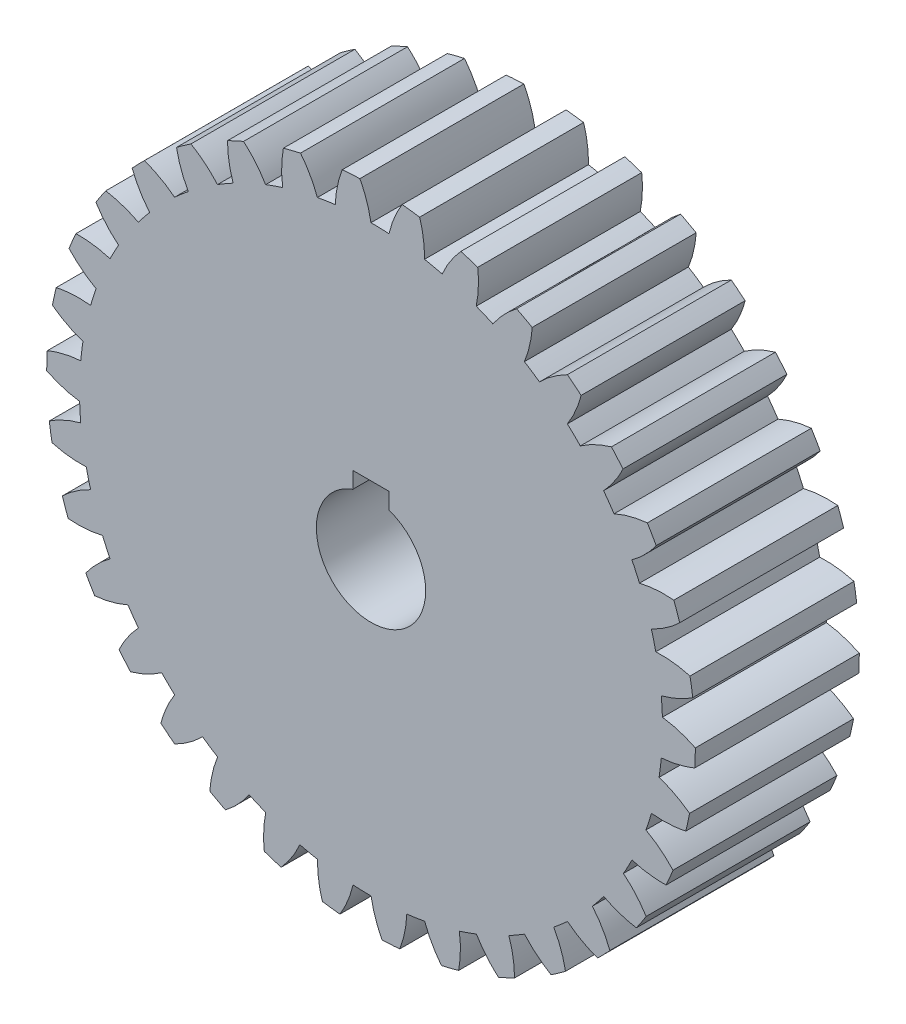
from build123d import *

# Parameters (mm, degrees)
SKETCH2_R           = 32
BOSS_EXTRUDE1_DEPTH = 18
BOSS_EXTRUDE2_DEPTH = 18
SKETCH4_R           = 6
CUT_EXTRUDE1_DEPTH  = 19.0000001
SKETCH5_W           = 4
SKETCH5_H           = 1.8
CUT_EXTRUDE2_DEPTH  = 8


with BuildPart() as part:
    # Sketch2 → Boss-Extrude1 (new body)
    with BuildSketch(Plane.XY):
        Circle(SKETCH2_R)
    extrude(amount=BOSS_EXTRUDE1_DEPTH)

    # Sketch3 → Boss-Extrude2 (add, through all)
    with BuildSketch(Plane.XY.offset(18)):
        with BuildLine():
            ThreePointArc((-0.008509696, 31.999998869), (-1.971036576, 31.939239421), (-3.926142805, 31.75823362))
            add(Edge.make_bspline(
                [(-3.926142805, 31.75823362), (-3.892964148, 32.765673981), (-3.66447612, 34.011686671), (-3.255661122, 35.204043024), (-3.15948732, 35.459521146)],
                knots=[0.00450438, 0.00450438, 0.00450438, 0.00450438, 0.249370947, 0.316995121, 0.316995121, 0.316995121, 0.316995121], degree=3))
            ThreePointArc((-3.15948732, 35.459521146), (-2.1927782, 35.532403856), (-1.224442977, 35.578936738))
            add(Edge.make_bspline(
                [(-0.008509696, 31.999998869), (-0.165307213, 32.995715259), (-0.545266131, 34.204179473), (-1.097586389, 35.337222282), (-1.224442977, 35.578936738)],
                knots=[0.004504381, 0.004504381, 0.004504381, 0.004504381, 0.249370947, 0.316995114, 0.316995114, 0.316995114, 0.316995114], degree=3))
        make_face()
        with BuildLine():
            ThreePointArc((5.334017961, 35.198128535), (4.373620091, 35.330319094), (3.409978868, 35.436309685))
            add(Edge.make_bspline(
                [(1.976267352, 31.938916189), (2.193997759, 32.923106401), (2.647549576, 34.105918793), (3.268498626, 35.202853454), (3.409978868, 35.436309685)],
                knots=[0.00450438, 0.00450438, 0.00450438, 0.00450438, 0.249370947, 0.316995121, 0.316995121, 0.316995121, 0.316995121], degree=3))
            ThreePointArc((1.976267352, 31.938916189), (3.931343911, 31.757590196), (5.87161956, 31.45670173))
            add(Edge.make_bspline(
                [(5.87161956, 31.45670173), (5.900454225, 32.464275625), (5.749019546, 33.721980707), (5.41429966, 34.937219891), (5.334017961, 35.198128535)],
                knots=[0.004504381, 0.004504381, 0.004504381, 0.004504381, 0.249370947, 0.316995114, 0.316995114, 0.316995114, 0.316995114], degree=3))
        make_face()
        with BuildLine():
            ThreePointArc((11.710835316, 33.618690281), (10.791079996, 33.92510269), (9.863322315, 34.2063572))
            add(Edge.make_bspline(
                [(7.811378094, 31.031957274), (8.206245705, 31.95938192), (8.869416146, 33.038714755), (9.681353574, 34.002872931), (9.863322315, 34.2063572)],
                knots=[0.00450438, 0.00450438, 0.00450438, 0.00450438, 0.249370947, 0.316995121, 0.316995121, 0.316995121, 0.316995121], degree=3))
            ThreePointArc((7.811378094, 31.031957274), (9.699847195, 30.494474326), (11.551797854, 29.842184343))
            add(Edge.make_bspline(
                [(11.551797854, 29.842184343), (11.765282772, 30.827304021), (11.847529259, 32.091420334), (11.741808228, 33.347472378), (11.710835316, 33.618690281)],
                knots=[0.004504381, 0.004504381, 0.004504381, 0.004504381, 0.249370947, 0.316995114, 0.316995114, 0.316995114, 0.316995114], degree=3))
        make_face()
        with BuildLine():
            ThreePointArc((17.688854219, 30.89440785), (16.841062613, 31.364607602), (15.980782151, 31.811548246))
            add(Edge.make_bspline(
                [(13.380481724, 29.068242273), (13.939039795, 29.907319019), (14.789245387, 30.846416912), (15.764521637, 31.644965352), (15.980782151, 31.811548246)],
                knots=[0.00450438, 0.00450438, 0.00450438, 0.00450438, 0.249370947, 0.316995121, 0.316995121, 0.316995121, 0.316995121], degree=3))
            ThreePointArc((13.380481724, 29.068242273), (15.138033817, 28.192905706), (16.838593527, 27.211427159))
            add(Edge.make_bspline(
                [(16.838593527, 27.211427159), (17.229458724, 28.140545553), (17.542585571, 29.36802513), (17.6694636, 30.62211669), (17.688854219, 30.89440785)],
                knots=[0.004504381, 0.004504381, 0.004504381, 0.004504381, 0.249370947, 0.316995114, 0.316995114, 0.316995114, 0.316995114], degree=3))
        make_face()
        with BuildLine():
            ThreePointArc((23.064500407, 27.118053414), (22.317543043, 27.73602842), (21.554035618, 28.333435171))
            add(Edge.make_bspline(
                [(18.493929097, 26.114643144), (19.197156602, 26.836798238), (20.205444614, 27.603681338), (21.310847823, 28.209426432), (21.554035618, 28.333435171)],
                knots=[0.00450438, 0.00450438, 0.00450438, 0.00450438, 0.249370947, 0.316995121, 0.316995121, 0.316995121, 0.316995121], degree=3))
            ThreePointArc((18.493929097, 26.114643144), (20.060712854, 24.931261496), (21.551971093, 23.65401746))
            add(Edge.make_bspline(
                [(21.551971093, 23.65401746), (22.106906124, 24.495494556), (22.640250172, 25.644537054), (22.995406581, 26.853961545), (23.064500407, 27.118053414)],
                knots=[0.004504381, 0.004504381, 0.004504381, 0.004504381, 0.249370947, 0.316995114, 0.316995114, 0.316995114, 0.316995114], degree=3))
        make_face()
        with BuildLine():
            ThreePointArc((27.654712697, 22.418226193), (27.03402631, 23.162932056), (26.393292253, 23.890460943))
            add(Edge.make_bspline(
                [(22.977587896, 22.271741165), (23.801537266, 22.85238248), (24.933571658, 23.420935502), (26.131458646, 23.813249328), (26.393292253, 23.890460943)],
                knots=[0.00450438, 0.00450438, 0.00450438, 0.00450438, 0.249370947, 0.316995121, 0.316995121, 0.316995121, 0.316995121], degree=3))
            ThreePointArc((22.977587896, 22.271741165), (24.300248374, 20.820613078), (25.531422133, 19.291098566))
            add(Edge.make_bspline(
                [(25.531422133, 19.291098566), (26.231529351, 20.016278871), (26.966928208, 21.047755025), (27.538268571, 22.171326948), (27.654712697, 22.418226193)],
                knots=[0.004504381, 0.004504381, 0.004504381, 0.004504381, 0.249370947, 0.316995114, 0.316995114, 0.316995114, 0.316995114], degree=3))
        make_face()
        with BuildLine():
            ThreePointArc((31.303176914, 16.954973167), (30.829898236, 17.801049822), (30.333756975, 18.633925721))
            add(Edge.make_bspline(
                [(26.678772497, 17.670401752), (27.595385126, 18.089756246), (28.812615825, 18.440617799), (30.062193987, 18.60614058), (30.333756975, 18.633925721)],
                knots=[0.00450438, 0.00450438, 0.00450438, 0.00450438, 0.249370947, 0.316995121, 0.316995121, 0.316995121, 0.316995121], degree=3))
            ThreePointArc((26.678772497, 17.670401752), (27.712268081, 16.000943653), (28.641431213, 14.271244448))
            add(Edge.make_bspline(
                [(28.641431213, 14.271244448), (29.462869307, 14.855432816), (30.375279846, 15.734216943), (31.143347853, 16.733674403), (31.303176914, 16.954973167)],
                knots=[0.004504381, 0.004504381, 0.004504381, 0.004504381, 0.249370947, 0.316995114, 0.316995114, 0.316995114, 0.316995114], degree=3))
        make_face()
        with BuildLine():
            ThreePointArc((33.885648985, 10.914338865), (33.575894953, 11.832974186), (33.241241985, 12.742834507))
            add(Edge.make_bspline(
                [(29.471443498, 12.467318), (30.449505242, 12.711105059), (31.710480916, 12.832326973), (32.969197366, 12.765422029), (33.241241985, 12.742834507)],
                knots=[0.00450438, 0.00450438, 0.00450438, 0.00450438, 0.249370947, 0.316995121, 0.316995121, 0.316995121, 0.316995121], degree=3))
            ThreePointArc((29.471443498, 12.467318), (30.180579736, 10.636381283), (30.776090704, 8.765400216))
            add(Edge.make_bspline(
                [(30.776090704, 8.765400216), (31.690886585, 9.188702814), (32.749237761, 9.884868975), (33.687877776, 10.726176645), (33.885648985, 10.914338865)],
                knots=[0.004504381, 0.004504381, 0.004504381, 0.004504381, 0.249370947, 0.316995114, 0.316995114, 0.316995114, 0.316995114], degree=3))
        make_face()
        with BuildLine():
            ThreePointArc((35.314185921, 4.502029843), (35.178504838, 5.461940806), (35.016736368, 6.417801348))
            add(Edge.make_bspline(
                [(31.260499839, 6.839674687), (32.266703977, 6.899592434), (33.528483612, 6.787046642), (34.753474272, 6.489992342), (35.016736368, 6.417801348)],
                knots=[0.00450438, 0.00450438, 0.00450438, 0.00450438, 0.249370947, 0.316995121, 0.316995121, 0.316995121, 0.316995121], degree=3))
            ThreePointArc((31.260499839, 6.839674687), (31.621127945, 4.909609705), (31.862707339, 2.961060793))
            add(Edge.make_bspline(
                [(31.862707339, 2.961060793), (32.839708729, 3.209062558), (34.007959662, 3.698903649), (35.085207426, 4.353411807), (35.314185921, 4.502029843)],
                knots=[0.004504381, 0.004504381, 0.004504381, 0.004504381, 0.249370947, 0.316995114, 0.316995114, 0.316995114, 0.316995114], degree=3))
        make_face()
        with BuildLine():
            ThreePointArc((35.540140611, -2.063590405), (35.583152932, -1.095092417), (35.599777791, -0.125782339))
            add(Edge.make_bspline(
                [(31.98501735, 0.979114456), (32.985098808, 0.853122464), (34.204714012, 0.510641579), (35.354263293, -0.006446251), (35.599777791, -0.125782339)],
                knots=[0.00450438, 0.00450438, 0.00450438, 0.00450438, 0.249370947, 0.316995121, 0.316995121, 0.316995121, 0.316995121], degree=3))
            ThreePointArc((31.98501735, 0.979114456), (31.984856568, -0.984352743), (31.86427769, -2.944114004))
            add(Edge.make_bspline(
                [(31.86427769, -2.944114004), (32.87021398, -2.879858475), (34.108581285, -2.613023405), (35.287752417, -2.167603249), (35.540140611, -2.063590405)],
                knots=[0.004504381, 0.004504381, 0.004504381, 0.004504381, 0.249370947, 0.316995114, 0.316995114, 0.316995114, 0.316995114], degree=3))
        make_face()
        with BuildLine():
            ThreePointArc((34.555818438, -8.558937557), (34.776059431, -7.614833581), (34.97051148, -6.665082659))
            add(Edge.make_bspline(
                [(31.620323457, -4.914788344), (32.58022566, -5.222399568), (33.7161439, -5.783152771), (34.751105281, -6.502665324), (34.97051148, -6.665082659)],
                knots=[0.00450438, 0.00450438, 0.00450438, 0.00450438, 0.249370947, 0.316995121, 0.316995121, 0.316995121, 0.316995121], degree=3))
            ThreePointArc((31.620323457, -4.914788344), (31.259379262, -6.844794238), (30.780748282, -8.749030529))
            add(Edge.make_bspline(
                [(30.780748282, -8.749030529), (31.781363517, -8.870709381), (33.04767608, -8.83596708), (34.288615323, -8.614803176), (34.555818438, -8.558937557)],
                knots=[0.004504381, 0.004504381, 0.004504381, 0.004504381, 0.249370947, 0.316995114, 0.316995114, 0.316995114, 0.316995114], degree=3))
        make_face()
        with BuildLine():
            ThreePointArc((32.394739313, -14.762820356), (32.784708935, -13.875260721), (33.150366342, -12.977411583))
            add(Edge.make_bspline(
                [(30.178837373, -10.641323921), (31.065872003, -11.120079046), (32.079410945, -11.880008789), (32.964540058, -12.777443929), (33.150366342, -12.977411583)],
                knots=[0.00450438, 0.00450438, 0.00450438, 0.00450438, 0.249370947, 0.316995121, 0.316995121, 0.316995121, 0.316995121], degree=3))
            ThreePointArc((30.178837373, -10.641323921), (29.469401286, -12.472144476), (28.649017408, -14.256009313))
            add(Edge.make_bspline(
                [(28.649017408, -14.256009313), (29.610236837, -14.559478918), (30.861371904, -14.758012494), (32.121820558, -14.768636313), (32.394739313, -14.762820356)],
                knots=[0.004504381, 0.004504381, 0.004504381, 0.004504381, 0.249370947, 0.316995114, 0.316995114, 0.316995114, 0.316995114], degree=3))
        make_face()
        with BuildLine():
            ThreePointArc((29.130496193, -20.463973014), (29.676914497, -19.663182498), (30.201325238, -18.847810321))
            add(Edge.make_bspline(
                [(27.709647178, -16.005481975), (28.493607334, -16.63907757), (29.350252126, -17.572305357), (30.055406959, -18.617102005), (30.201325238, -18.847810321)],
                knots=[0.00450438, 0.00450438, 0.00450438, 0.00450438, 0.249370947, 0.316995121, 0.316995121, 0.316995121, 0.316995121], degree=3))
            ThreePointArc((27.709647178, -16.005481975), (26.675878195, -17.674770792), (25.541678607, -19.277516798))
            add(Edge.make_bspline(
                [(25.541678607, -19.277516798), (26.430769055, -19.752442863), (27.624120721, -20.177491493), (28.86115572, -20.419541254), (29.130496193, -20.463973014)],
                knots=[0.004504381, 0.004504381, 0.004504381, 0.004504381, 0.249370947, 0.316995114, 0.316995114, 0.316995114, 0.316995114], degree=3))
        make_face()
        with BuildLine():
            ThreePointArc((24.874248965, -25.468249615), (25.558508329, -24.781498179), (26.223814225, -24.076369483))
            add(Edge.make_bspline(
                [(24.296838183, -20.824592537), (24.951027042, -21.591452263), (25.621605673, -22.666198141), (26.122773024, -23.822777002), (26.223814225, -24.076369483)],
                knots=[0.00450438, 0.00450438, 0.00450438, 0.00450438, 0.249370947, 0.316995121, 0.316995121, 0.316995121, 0.316995121], degree=3))
            ThreePointArc((24.296838183, -20.824592537), (22.973940065, -22.275503987), (21.564548575, -23.64255157))
            add(Edge.make_bspline(
                [(21.564548575, -23.64255157), (22.351233133, -24.272761057), (23.446163238, -24.90985022), (24.617658839, -25.375083207), (24.874248965, -25.468249615)],
                knots=[0.004504381, 0.004504381, 0.004504381, 0.004504381, 0.249370947, 0.316995114, 0.316995114, 0.316995114, 0.316995114], degree=3))
        make_face()
        with BuildLine():
            ThreePointArc((19.770939021, -29.605235521), (20.569737814, -29.055909661), (21.353282671, -28.485036759))
            add(Edge.make_bspline(
                [(20.056629504, -24.934546576), (20.558769449, -25.808555946), (21.020446168, -26.988220733), (21.300559385, -28.2171959), (21.353282671, -28.485036759)],
                knots=[0.00450438, 0.00450438, 0.00450438, 0.00450438, 0.249370947, 0.316995121, 0.316995121, 0.316995121, 0.316995121], degree=3))
            ThreePointArc((20.056629504, -24.934546576), (18.489651961, -26.117671611), (16.853063706, -27.202467604))
            add(Edge.make_bspline(
                [(16.853063706, -27.202467604), (17.510552775, -27.966499485), (18.469774787, -28.793933873), (19.535837112, -29.466507136), (19.770939021, -29.605235521)],
                knots=[0.004504381, 0.004504381, 0.004504381, 0.004504381, 0.249370947, 0.316995114, 0.316995114, 0.316995114, 0.316995114], degree=3))
        make_face()
        with BuildLine():
            ThreePointArc((13.994353461, -32.734050639), (14.880489549, -32.340856989), (15.755590686, -31.923680272))
            add(Edge.make_bspline(
                [(15.133416362, -28.195384537), (15.466407621, -29.14678021), (15.70346058, -30.391191837), (15.752980743, -31.650712034), (15.755590686, -31.923680272)],
                knots=[0.00450438, 0.00450438, 0.00450438, 0.00450438, 0.249370947, 0.316995121, 0.316995121, 0.316995121, 0.316995121], degree=3))
            ThreePointArc((15.133416362, -28.195384537), (13.375720935, -29.070433252), (11.567667964, -29.836036229))
            add(Edge.make_bspline(
                [(11.567667964, -29.836036229), (12.073571543, -30.707872315), (12.864420308, -31.697474642), (13.788745883, -32.554484506), (13.994353461, -32.734050639)],
                knots=[0.004504381, 0.004504381, 0.004504381, 0.004504381, 0.249370947, 0.316995114, 0.316995114, 0.316995114, 0.316995114], degree=3))
        make_face()
        with BuildLine():
            ThreePointArc((7.741206979, -34.748146922), (8.68450406, -34.52447522), (9.621360957, -34.275201142))
            add(Edge.make_bspline(
                [(9.694852877, -30.496062495), (9.84735583, -31.492445831), (9.851712476, -32.759227353), (9.668953235, -34.006401131), (9.621360957, -34.275201142)],
                knots=[0.00450438, 0.00450438, 0.00450438, 0.00450438, 0.249370947, 0.316995121, 0.316995121, 0.316995121, 0.316995121], degree=3))
            ThreePointArc((9.694852877, -30.496062495), (7.806295776, -31.033236155), (5.888349164, -31.453574425))
            add(Edge.make_bspline(
                [(5.888349164, -31.453574425), (6.225439312, -32.403525384), (6.820983424, -33.52159593), (7.572095451, -34.533857951), (7.741206979, -34.748146922)],
                knots=[0.004504381, 0.004504381, 0.004504381, 0.004504381, 0.249370947, 0.316995114, 0.316995114, 0.316995114, 0.316995114], degree=3))
        make_face()
        with BuildLine():
            ThreePointArc((1.224442977, -35.578936738), (2.1927782, -35.532403856), (3.15948732, -35.459521146))
            add(Edge.make_bspline(
                [(3.926142805, -31.75823362), (3.892964148, -32.765673981), (3.66447612, -34.011686671), (3.255661122, -35.204043024), (3.15948732, -35.459521146)],
                knots=[0.00450438, 0.00450438, 0.00450438, 0.00450438, 0.249370947, 0.316995121, 0.316995121, 0.316995121, 0.316995121], degree=3))
            ThreePointArc((3.926142805, -31.75823362), (1.971036576, -31.939239421), (0.008509696, -31.999998869))
            add(Edge.make_bspline(
                [(0.008509696, -31.999998869), (0.165307213, -32.995715259), (0.545266131, -34.204179473), (1.097586389, -35.337222282), (1.224442977, -35.578936738)],
                knots=[0.004504381, 0.004504381, 0.004504381, 0.004504381, 0.249370947, 0.316995114, 0.316995114, 0.316995114, 0.316995114], degree=3))
        make_face()
        with BuildLine():
            ThreePointArc((-5.334017961, -35.198128535), (-4.373620091, -35.330319094), (-3.409978868, -35.436309685))
            add(Edge.make_bspline(
                [(-1.976267352, -31.938916189), (-2.193997759, -32.923106401), (-2.647549576, -34.105918793), (-3.268498626, -35.202853454), (-3.409978868, -35.436309685)],
                knots=[0.00450438, 0.00450438, 0.00450438, 0.00450438, 0.249370947, 0.316995121, 0.316995121, 0.316995121, 0.316995121], degree=3))
            ThreePointArc((-1.976267352, -31.938916189), (-3.931343911, -31.757590196), (-5.87161956, -31.45670173))
            add(Edge.make_bspline(
                [(-5.87161956, -31.45670173), (-5.900454225, -32.464275625), (-5.749019546, -33.721980707), (-5.41429966, -34.937219891), (-5.334017961, -35.198128535)],
                knots=[0.004504381, 0.004504381, 0.004504381, 0.004504381, 0.249370947, 0.316995114, 0.316995114, 0.316995114, 0.316995114], degree=3))
        make_face()
        with BuildLine():
            ThreePointArc((-11.710835316, -33.618690281), (-10.791079996, -33.92510269), (-9.863322315, -34.2063572))
            add(Edge.make_bspline(
                [(-7.811378094, -31.031957274), (-8.206245705, -31.95938192), (-8.869416146, -33.038714755), (-9.681353574, -34.002872931), (-9.863322315, -34.2063572)],
                knots=[0.00450438, 0.00450438, 0.00450438, 0.00450438, 0.249370947, 0.316995121, 0.316995121, 0.316995121, 0.316995121], degree=3))
            ThreePointArc((-7.811378094, -31.031957274), (-9.699847195, -30.494474326), (-11.551797854, -29.842184343))
            add(Edge.make_bspline(
                [(-11.551797854, -29.842184343), (-11.765282772, -30.827304021), (-11.847529259, -32.091420334), (-11.741808228, -33.347472378), (-11.710835316, -33.618690281)],
                knots=[0.004504381, 0.004504381, 0.004504381, 0.004504381, 0.249370947, 0.316995114, 0.316995114, 0.316995114, 0.316995114], degree=3))
        make_face()
        with BuildLine():
            ThreePointArc((-17.688854219, -30.89440785), (-16.841062613, -31.364607602), (-15.980782151, -31.811548246))
            add(Edge.make_bspline(
                [(-13.380481724, -29.068242273), (-13.939039795, -29.907319019), (-14.789245387, -30.846416912), (-15.764521637, -31.644965352), (-15.980782151, -31.811548246)],
                knots=[0.00450438, 0.00450438, 0.00450438, 0.00450438, 0.249370947, 0.316995121, 0.316995121, 0.316995121, 0.316995121], degree=3))
            ThreePointArc((-13.380481724, -29.068242273), (-15.138033817, -28.192905706), (-16.838593527, -27.211427159))
            add(Edge.make_bspline(
                [(-16.838593527, -27.211427159), (-17.229458724, -28.140545553), (-17.542585571, -29.36802513), (-17.6694636, -30.62211669), (-17.688854219, -30.89440785)],
                knots=[0.004504381, 0.004504381, 0.004504381, 0.004504381, 0.249370947, 0.316995114, 0.316995114, 0.316995114, 0.316995114], degree=3))
        make_face()
        with BuildLine():
            ThreePointArc((-23.064500407, -27.118053414), (-22.317543043, -27.73602842), (-21.554035618, -28.333435171))
            add(Edge.make_bspline(
                [(-18.493929097, -26.114643144), (-19.197156602, -26.836798238), (-20.205444614, -27.603681338), (-21.310847823, -28.209426432), (-21.554035618, -28.333435171)],
                knots=[0.00450438, 0.00450438, 0.00450438, 0.00450438, 0.249370947, 0.316995121, 0.316995121, 0.316995121, 0.316995121], degree=3))
            ThreePointArc((-18.493929097, -26.114643144), (-20.060712854, -24.931261496), (-21.551971093, -23.65401746))
            add(Edge.make_bspline(
                [(-21.551971093, -23.65401746), (-22.106906124, -24.495494556), (-22.640250172, -25.644537054), (-22.995406581, -26.853961545), (-23.064500407, -27.118053414)],
                knots=[0.004504381, 0.004504381, 0.004504381, 0.004504381, 0.249370947, 0.316995114, 0.316995114, 0.316995114, 0.316995114], degree=3))
        make_face()
        with BuildLine():
            ThreePointArc((-27.654712697, -22.418226193), (-27.03402631, -23.162932056), (-26.393292253, -23.890460943))
            add(Edge.make_bspline(
                [(-22.977587896, -22.271741165), (-23.801537266, -22.85238248), (-24.933571658, -23.420935502), (-26.131458646, -23.813249328), (-26.393292253, -23.890460943)],
                knots=[0.00450438, 0.00450438, 0.00450438, 0.00450438, 0.249370947, 0.316995121, 0.316995121, 0.316995121, 0.316995121], degree=3))
            ThreePointArc((-22.977587896, -22.271741165), (-24.300248374, -20.820613078), (-25.531422133, -19.291098566))
            add(Edge.make_bspline(
                [(-25.531422133, -19.291098566), (-26.231529351, -20.016278871), (-26.966928208, -21.047755025), (-27.538268571, -22.171326948), (-27.654712697, -22.418226193)],
                knots=[0.004504381, 0.004504381, 0.004504381, 0.004504381, 0.249370947, 0.316995114, 0.316995114, 0.316995114, 0.316995114], degree=3))
        make_face()
        with BuildLine():
            ThreePointArc((-31.303176914, -16.954973167), (-30.829898236, -17.801049822), (-30.333756975, -18.633925721))
            add(Edge.make_bspline(
                [(-26.678772497, -17.670401752), (-27.595385126, -18.089756246), (-28.812615825, -18.440617799), (-30.062193987, -18.60614058), (-30.333756975, -18.633925721)],
                knots=[0.00450438, 0.00450438, 0.00450438, 0.00450438, 0.249370947, 0.316995121, 0.316995121, 0.316995121, 0.316995121], degree=3))
            ThreePointArc((-26.678772497, -17.670401752), (-27.712268081, -16.000943653), (-28.641431213, -14.271244448))
            add(Edge.make_bspline(
                [(-28.641431213, -14.271244448), (-29.462869307, -14.855432816), (-30.375279846, -15.734216943), (-31.143347853, -16.733674403), (-31.303176914, -16.954973167)],
                knots=[0.004504381, 0.004504381, 0.004504381, 0.004504381, 0.249370947, 0.316995114, 0.316995114, 0.316995114, 0.316995114], degree=3))
        make_face()
        with BuildLine():
            ThreePointArc((-33.885648985, -10.914338865), (-33.575894953, -11.832974186), (-33.241241985, -12.742834507))
            add(Edge.make_bspline(
                [(-29.471443498, -12.467318), (-30.449505242, -12.711105059), (-31.710480916, -12.832326973), (-32.969197366, -12.765422029), (-33.241241985, -12.742834507)],
                knots=[0.00450438, 0.00450438, 0.00450438, 0.00450438, 0.249370947, 0.316995121, 0.316995121, 0.316995121, 0.316995121], degree=3))
            ThreePointArc((-29.471443498, -12.467318), (-30.180579736, -10.636381283), (-30.776090704, -8.765400216))
            add(Edge.make_bspline(
                [(-30.776090704, -8.765400216), (-31.690886585, -9.188702814), (-32.749237761, -9.884868975), (-33.687877776, -10.726176645), (-33.885648985, -10.914338865)],
                knots=[0.004504381, 0.004504381, 0.004504381, 0.004504381, 0.249370947, 0.316995114, 0.316995114, 0.316995114, 0.316995114], degree=3))
        make_face()
        with BuildLine():
            ThreePointArc((-35.314185921, -4.502029843), (-35.178504838, -5.461940806), (-35.016736368, -6.417801348))
            add(Edge.make_bspline(
                [(-31.260499839, -6.839674687), (-32.266703977, -6.899592434), (-33.528483612, -6.787046642), (-34.753474272, -6.489992342), (-35.016736368, -6.417801348)],
                knots=[0.00450438, 0.00450438, 0.00450438, 0.00450438, 0.249370947, 0.316995121, 0.316995121, 0.316995121, 0.316995121], degree=3))
            ThreePointArc((-31.260499839, -6.839674687), (-31.621127945, -4.909609705), (-31.862707339, -2.961060793))
            add(Edge.make_bspline(
                [(-31.862707339, -2.961060793), (-32.839708729, -3.209062558), (-34.007959662, -3.698903649), (-35.085207426, -4.353411807), (-35.314185921, -4.502029843)],
                knots=[0.004504381, 0.004504381, 0.004504381, 0.004504381, 0.249370947, 0.316995114, 0.316995114, 0.316995114, 0.316995114], degree=3))
        make_face()
        with BuildLine():
            ThreePointArc((-35.540140611, 2.063590405), (-35.583152932, 1.095092417), (-35.599777791, 0.125782339))
            add(Edge.make_bspline(
                [(-31.98501735, -0.979114456), (-32.985098808, -0.853122464), (-34.204714012, -0.510641579), (-35.354263293, 0.006446251), (-35.599777791, 0.125782339)],
                knots=[0.00450438, 0.00450438, 0.00450438, 0.00450438, 0.249370947, 0.316995121, 0.316995121, 0.316995121, 0.316995121], degree=3))
            ThreePointArc((-31.98501735, -0.979114456), (-31.984856568, 0.984352743), (-31.86427769, 2.944114004))
            add(Edge.make_bspline(
                [(-31.86427769, 2.944114004), (-32.87021398, 2.879858475), (-34.108581285, 2.613023405), (-35.287752417, 2.167603249), (-35.540140611, 2.063590405)],
                knots=[0.004504381, 0.004504381, 0.004504381, 0.004504381, 0.249370947, 0.316995114, 0.316995114, 0.316995114, 0.316995114], degree=3))
        make_face()
        with BuildLine():
            ThreePointArc((-34.555818438, 8.558937557), (-34.776059431, 7.614833581), (-34.97051148, 6.665082659))
            add(Edge.make_bspline(
                [(-31.620323457, 4.914788344), (-32.58022566, 5.222399568), (-33.7161439, 5.783152771), (-34.751105281, 6.502665324), (-34.97051148, 6.665082659)],
                knots=[0.00450438, 0.00450438, 0.00450438, 0.00450438, 0.249370947, 0.316995121, 0.316995121, 0.316995121, 0.316995121], degree=3))
            ThreePointArc((-31.620323457, 4.914788344), (-31.259379262, 6.844794238), (-30.780748282, 8.749030529))
            add(Edge.make_bspline(
                [(-30.780748282, 8.749030529), (-31.781363517, 8.870709381), (-33.04767608, 8.83596708), (-34.288615323, 8.614803176), (-34.555818438, 8.558937557)],
                knots=[0.004504381, 0.004504381, 0.004504381, 0.004504381, 0.249370947, 0.316995114, 0.316995114, 0.316995114, 0.316995114], degree=3))
        make_face()
        with BuildLine():
            ThreePointArc((-32.394739313, 14.762820356), (-32.784708935, 13.875260721), (-33.150366342, 12.977411583))
            add(Edge.make_bspline(
                [(-30.178837373, 10.641323921), (-31.065872003, 11.120079046), (-32.079410945, 11.880008789), (-32.964540058, 12.777443929), (-33.150366342, 12.977411583)],
                knots=[0.00450438, 0.00450438, 0.00450438, 0.00450438, 0.249370947, 0.316995121, 0.316995121, 0.316995121, 0.316995121], degree=3))
            ThreePointArc((-30.178837373, 10.641323921), (-29.469401286, 12.472144476), (-28.649017408, 14.256009313))
            add(Edge.make_bspline(
                [(-28.649017408, 14.256009313), (-29.610236837, 14.559478918), (-30.861371904, 14.758012494), (-32.121820558, 14.768636313), (-32.394739313, 14.762820356)],
                knots=[0.004504381, 0.004504381, 0.004504381, 0.004504381, 0.249370947, 0.316995114, 0.316995114, 0.316995114, 0.316995114], degree=3))
        make_face()
        with BuildLine():
            ThreePointArc((-29.130496193, 20.463973014), (-29.676914497, 19.663182498), (-30.201325238, 18.847810321))
            add(Edge.make_bspline(
                [(-27.709647178, 16.005481975), (-28.493607334, 16.63907757), (-29.350252126, 17.572305357), (-30.055406959, 18.617102005), (-30.201325238, 18.847810321)],
                knots=[0.00450438, 0.00450438, 0.00450438, 0.00450438, 0.249370947, 0.316995121, 0.316995121, 0.316995121, 0.316995121], degree=3))
            ThreePointArc((-27.709647178, 16.005481975), (-26.675878195, 17.674770792), (-25.541678607, 19.277516798))
            add(Edge.make_bspline(
                [(-25.541678607, 19.277516798), (-26.430769055, 19.752442863), (-27.624120721, 20.177491493), (-28.86115572, 20.419541254), (-29.130496193, 20.463973014)],
                knots=[0.004504381, 0.004504381, 0.004504381, 0.004504381, 0.249370947, 0.316995114, 0.316995114, 0.316995114, 0.316995114], degree=3))
        make_face()
        with BuildLine():
            ThreePointArc((-24.874248965, 25.468249615), (-25.558508329, 24.781498179), (-26.223814225, 24.076369483))
            add(Edge.make_bspline(
                [(-24.296838183, 20.824592537), (-24.951027042, 21.591452263), (-25.621605673, 22.666198141), (-26.122773024, 23.822777002), (-26.223814225, 24.076369483)],
                knots=[0.00450438, 0.00450438, 0.00450438, 0.00450438, 0.249370947, 0.316995121, 0.316995121, 0.316995121, 0.316995121], degree=3))
            ThreePointArc((-24.296838183, 20.824592537), (-22.973940065, 22.275503987), (-21.564548575, 23.64255157))
            add(Edge.make_bspline(
                [(-21.564548575, 23.64255157), (-22.351233133, 24.272761057), (-23.446163238, 24.90985022), (-24.617658839, 25.375083207), (-24.874248965, 25.468249615)],
                knots=[0.004504381, 0.004504381, 0.004504381, 0.004504381, 0.249370947, 0.316995114, 0.316995114, 0.316995114, 0.316995114], degree=3))
        make_face()
        with BuildLine():
            ThreePointArc((-19.770939021, 29.605235521), (-20.569737814, 29.055909661), (-21.353282671, 28.485036759))
            add(Edge.make_bspline(
                [(-20.056629504, 24.934546576), (-20.558769449, 25.808555946), (-21.020446168, 26.988220733), (-21.300559385, 28.2171959), (-21.353282671, 28.485036759)],
                knots=[0.00450438, 0.00450438, 0.00450438, 0.00450438, 0.249370947, 0.316995121, 0.316995121, 0.316995121, 0.316995121], degree=3))
            ThreePointArc((-20.056629504, 24.934546576), (-18.489651961, 26.117671611), (-16.853063706, 27.202467604))
            add(Edge.make_bspline(
                [(-16.853063706, 27.202467604), (-17.510552775, 27.966499485), (-18.469774787, 28.793933873), (-19.535837112, 29.466507136), (-19.770939021, 29.605235521)],
                knots=[0.004504381, 0.004504381, 0.004504381, 0.004504381, 0.249370947, 0.316995114, 0.316995114, 0.316995114, 0.316995114], degree=3))
        make_face()
        with BuildLine():
            ThreePointArc((-13.994353461, 32.734050639), (-14.880489549, 32.340856989), (-15.755590686, 31.923680272))
            add(Edge.make_bspline(
                [(-15.133416362, 28.195384537), (-15.466407621, 29.14678021), (-15.70346058, 30.391191837), (-15.752980743, 31.650712034), (-15.755590686, 31.923680272)],
                knots=[0.00450438, 0.00450438, 0.00450438, 0.00450438, 0.249370947, 0.316995121, 0.316995121, 0.316995121, 0.316995121], degree=3))
            ThreePointArc((-15.133416362, 28.195384537), (-13.375720935, 29.070433252), (-11.567667964, 29.836036229))
            add(Edge.make_bspline(
                [(-11.567667964, 29.836036229), (-12.073571543, 30.707872315), (-12.864420308, 31.697474642), (-13.788745883, 32.554484506), (-13.994353461, 32.734050639)],
                knots=[0.004504381, 0.004504381, 0.004504381, 0.004504381, 0.249370947, 0.316995114, 0.316995114, 0.316995114, 0.316995114], degree=3))
        make_face()
        with BuildLine():
            ThreePointArc((-7.741206979, 34.748146922), (-8.68450406, 34.52447522), (-9.621360957, 34.275201142))
            add(Edge.make_bspline(
                [(-9.694852877, 30.496062495), (-9.84735583, 31.492445831), (-9.851712476, 32.759227353), (-9.668953235, 34.006401131), (-9.621360957, 34.275201142)],
                knots=[0.00450438, 0.00450438, 0.00450438, 0.00450438, 0.249370947, 0.316995121, 0.316995121, 0.316995121, 0.316995121], degree=3))
            ThreePointArc((-9.694852877, 30.496062495), (-7.806295776, 31.033236155), (-5.888349164, 31.453574425))
            add(Edge.make_bspline(
                [(-5.888349164, 31.453574425), (-6.225439312, 32.403525384), (-6.820983424, 33.52159593), (-7.572095451, 34.533857951), (-7.741206979, 34.748146922)],
                knots=[0.004504381, 0.004504381, 0.004504381, 0.004504381, 0.249370947, 0.316995114, 0.316995114, 0.316995114, 0.316995114], degree=3))
        make_face()
    extrude(amount=-BOSS_EXTRUDE2_DEPTH)

    # Sketch4 → Cut-Extrude1 (cut, through all)
    with BuildSketch(Plane.XY.offset(18)):
        Circle(SKETCH4_R)
    extrude(amount=-CUT_EXTRUDE1_DEPTH, mode=Mode.SUBTRACT)

    # Sketch5 → Cut-Extrude2 (cut)
    with BuildSketch(Plane.XY.offset(18)):
        with Locations((0, 6.556854249)):
            Rectangle(SKETCH5_W, SKETCH5_H)
    extrude(amount=-CUT_EXTRUDE2_DEPTH, mode=Mode.SUBTRACT)


solid = part.part
